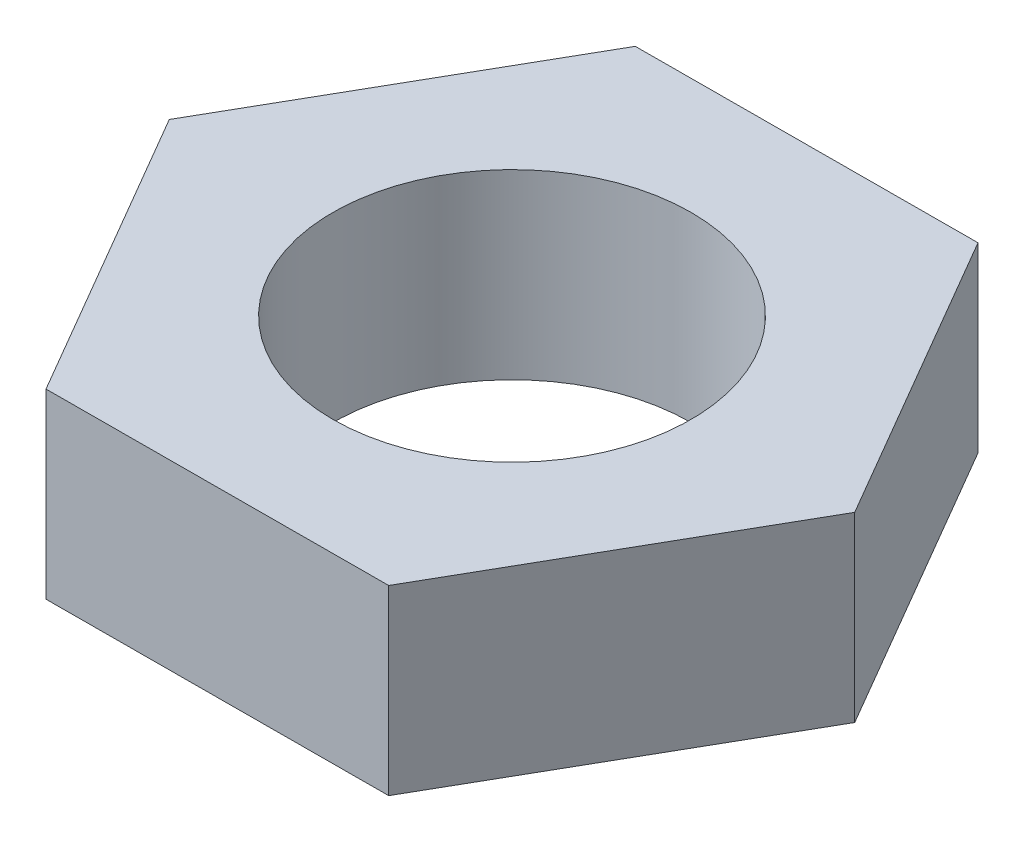
from build123d import *

# Parameters (mm, degrees)
BOSS_EXTRUDE1_DEPTH = 8.255
SKETCH2_R           = 8.128
CUT_EXTRUDE1_DEPTH  = 9.255


with BuildPart() as part:
    # Sketch1 → Boss-Extrude1 (new body)
    with BuildSketch(Plane(origin=(0, 0, 0), x_dir=(1, 0, 0), z_dir=(0, 1, 0))):
        Polygon((7.693812666, 13.439455367), (-7.792003428, 13.382764905), (-15.485816094, -0.056690463), (-7.693812666, -13.439455367), (7.792003428, -13.382764905), (15.485816094, 0.056690463), align=None)
    extrude(amount=BOSS_EXTRUDE1_DEPTH)

    # Sketch2 → Cut-Extrude1 (cut, through all)
    with BuildSketch(Plane(origin=(0, 8.255, 0), x_dir=(1, 0, 0), z_dir=(0, 1, 0))):
        Circle(SKETCH2_R)
    extrude(amount=-CUT_EXTRUDE1_DEPTH, mode=Mode.SUBTRACT)


solid = part.part
